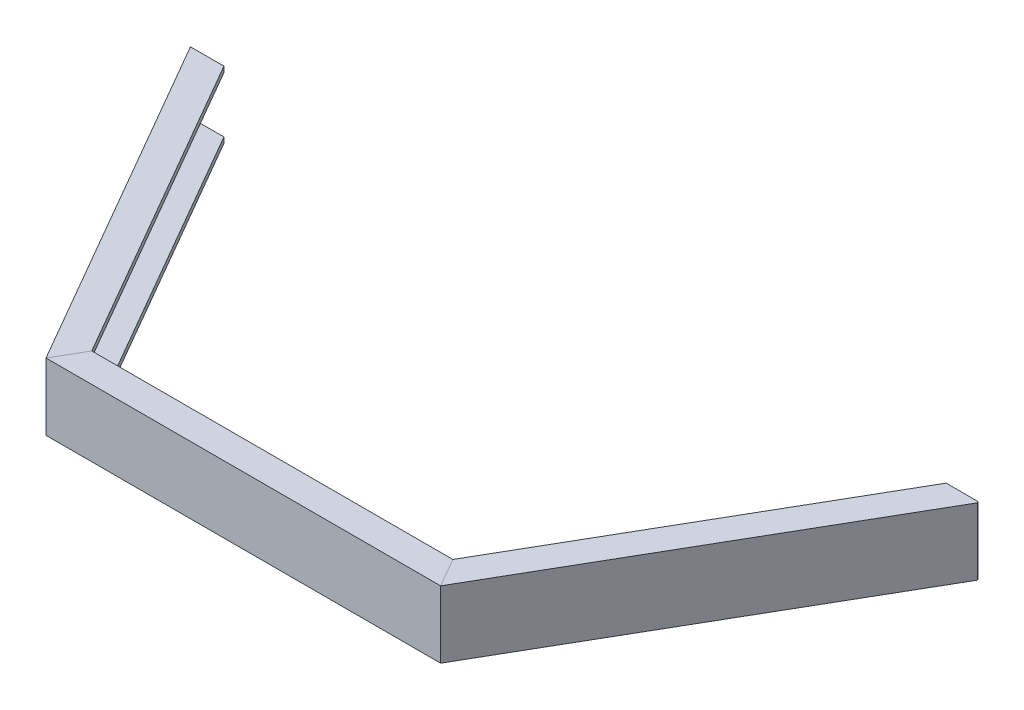
from build123d import *

# Parameters (mm, degrees)
SKETCH2_W          = 3101.423278338
SKETCH2_H          = 415.694779912
CUT_EXTRUDE1_DEPTH = 42.13622064


with BuildPart() as part:
    # Sweep1: sweep along a curve in space
    with BuildLine() as sweep1_path:
        Line((-586.587873497, 0, 0), (-293.293936748, 0.000279204, 508))
        Line((-293.293936748, 0.000279204, 508), (293.293936748, -0.000279204, 508))
        Line((293.293936748, -0.000279204, 508), (586.587873497, 0, 0))
    # Sketch1 → Sweep1 (sweep)
    with BuildSketch(Plane.XY):
        with BuildLine():
            Line((-539.087873497, 49.201467287), (-589.087873497, 49.201467287))
            Line((-589.087873497, 49.201467287), (-589.087873497, -50.798532713))
            Line((-589.087873497, -50.798532713), (-539.087873497, -50.798532713))
            Line((-539.087873497, -50.798532713), (-539.087873497, -42.298532713))
            Line((-539.087873497, -42.298532713), (-575.087873497, -42.298532713))
            ThreePointArc((-575.087873497, -42.298532713), (-581.451834528, -39.662493744), (-584.087873497, -33.298532713))
            Line((-584.087873497, -33.298532713), (-584.087873497, 31.701467287))
            ThreePointArc((-584.087873497, 31.701467287), (-581.451834528, 38.065428317), (-575.087873497, 40.701467287))
            Line((-575.087873497, 40.701467287), (-539.087873497, 40.701467287))
            Line((-539.087873497, 40.701467287), (-539.087873497, 49.201467287))
        make_face()
    sweep(path=sweep1_path.line, transition=Transition.RIGHT)

    # Sketch2 → Cut-Extrude1 (cut, through all)
    with BuildSketch(Plane.XY):
        Rectangle(SKETCH2_W, SKETCH2_H)
    extrude(amount=-CUT_EXTRUDE1_DEPTH, mode=Mode.SUBTRACT)


solid = part.part
